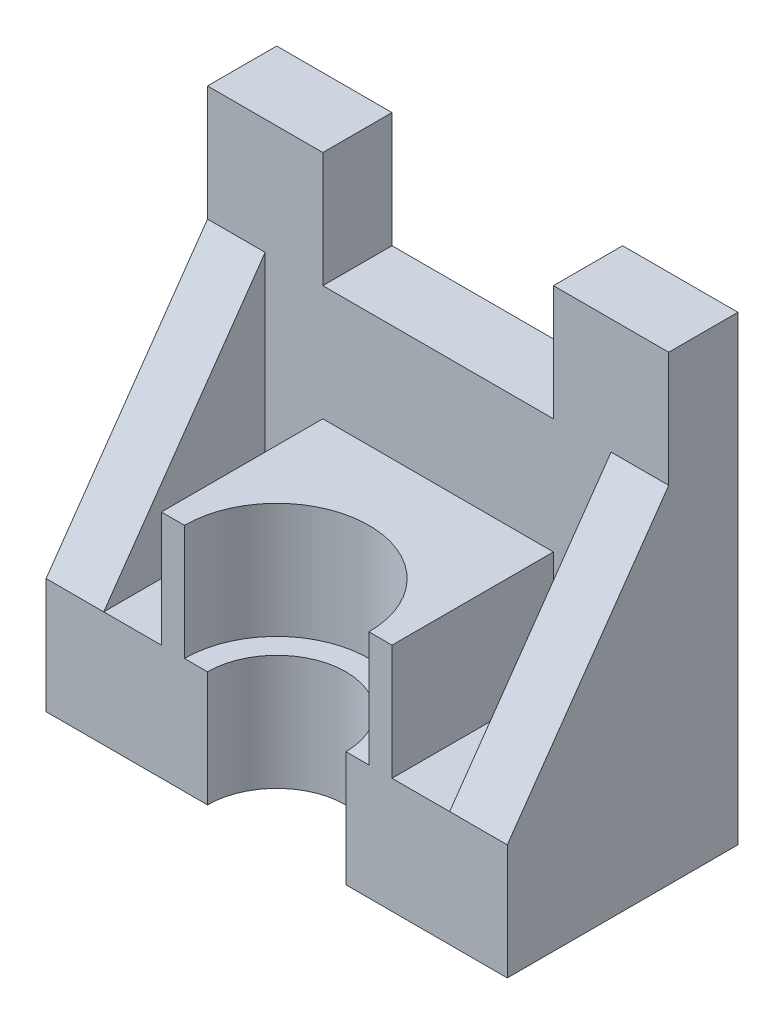
from build123d import *

# Parameters (mm, degrees)
BOSS_EXTRUDE1_DEPTH = 50
BOSS_EXTRUDE2_DEPTH = 15
SKETCH3_R           = 15
CUT_EXTRUDE3_DEPTH  = 150
SKETCH3_3_R         = 20
SKETCH3_3_R_2       = 15
CUT_EXTRUDE4_DEPTH  = 25
CUT_EXTRUDE7_DEPTH  = 20
CUT_EXTRUDE8_DEPTH  = 20


with BuildPart() as part:
    # Sketch1 → Boss-Extrude1 (new body)
    with BuildSketch(Plane.XY):
        Polygon((-51.239919355, -32.714717742), (48.760080645, -32.714717742), (48.760080645, 42.285282258), (36.260080645, 42.285282258), (36.260080645, -7.714717742), (23.760080645, -7.714717742), (23.760080645, 17.285282258), (-26.239919355, 17.285282258), (-26.239919355, -7.714717742), (-38.739919355, -7.714717742), (-38.739919355, 42.285282258), (-51.239919355, 42.285282258), align=None)
    extrude(amount=BOSS_EXTRUDE1_DEPTH)

    # Sketch1_3 → Boss-Extrude2 (add)
    with BuildSketch(Plane.XY):
        Polygon((-38.739919355, 42.285282258), (-38.739919355, -7.714717742), (-26.239919355, -7.714717742), (-26.239919355, 17.285282258), (23.760080645, 17.285282258), (23.760080645, -7.714717742), (36.260080645, -7.714717742), (36.260080645, 42.285282258), (48.760080645, 42.285282258), (48.760080645, 67.285282258), (23.760080645, 67.285282258), (23.760080645, 42.285282258), (-26.239919355, 42.285282258), (-26.239919355, 67.285282258), (-51.239919355, 67.285282258), (-51.239919355, 42.285282258), align=None)
    extrude(amount=BOSS_EXTRUDE2_DEPTH)

    # Sketch3 → Cut-Extrude3 (cut)
    with BuildSketch(Plane(origin=(0, 17.285282258, 0), x_dir=(1, 0, 0), z_dir=(0, 1, 0))):
        with Locations((-1.239919355, -50)):
            Circle(SKETCH3_R)
    extrude(amount=-CUT_EXTRUDE3_DEPTH, mode=Mode.SUBTRACT)

    # Sketch3_3 → Cut-Extrude4 (cut)
    with BuildSketch(Plane(origin=(0, 17.285282258, 0), x_dir=(1, 0, 0), z_dir=(0, 1, 0))):
        with Locations((-1.239919355, -50)):
            Circle(SKETCH3_3_R)
        with Locations((-1.239919355, -50)):
            Circle(SKETCH3_3_R_2, mode=Mode.SUBTRACT)
    extrude(amount=-CUT_EXTRUDE4_DEPTH, mode=Mode.SUBTRACT)

    # Sketch6 → Cut-Extrude7 (cut)
    with BuildSketch(Plane(origin=(48.760080645, 0, 0), x_dir=(0, 0, -1), z_dir=(1, 0, 0))):
        Polygon((-50, 42.285282258), (-50, -7.714717742), (-15, 42.285282258), align=None)
    extrude(amount=-CUT_EXTRUDE7_DEPTH, mode=Mode.SUBTRACT)

    # Sketch7 → Cut-Extrude8 (cut)
    with BuildSketch(Plane(origin=(-38.739919355, 0, 0), x_dir=(0, 0, -1), z_dir=(1, 0, 0))):
        Polygon((-50, -7.714717742), (-15, 42.285282258), (-50, 42.285282258), align=None)
    extrude(amount=-CUT_EXTRUDE8_DEPTH, mode=Mode.SUBTRACT)


solid = part.part
